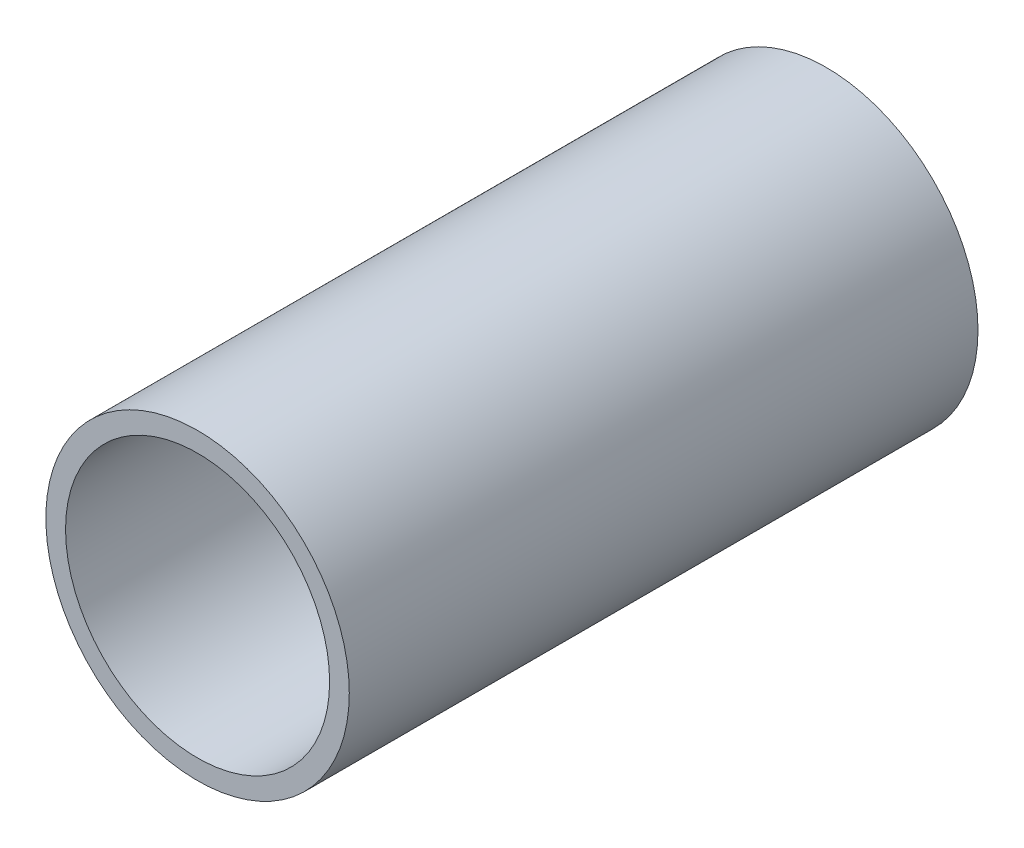
from build123d import *

# Parameters (mm, degrees)
CROQUIS1_R              = 30.165
CROQUIS1_R_2            = 26.25
SALIENTE_EXTRUIR1_DEPTH = 125


with BuildPart() as part:
    # Croquis1 → Saliente-Extruir1 (new body)
    with BuildSketch(Plane.XY):
        Circle(CROQUIS1_R)
        Circle(CROQUIS1_R_2, mode=Mode.SUBTRACT)
    extrude(amount=SALIENTE_EXTRUIR1_DEPTH)


solid = part.part
